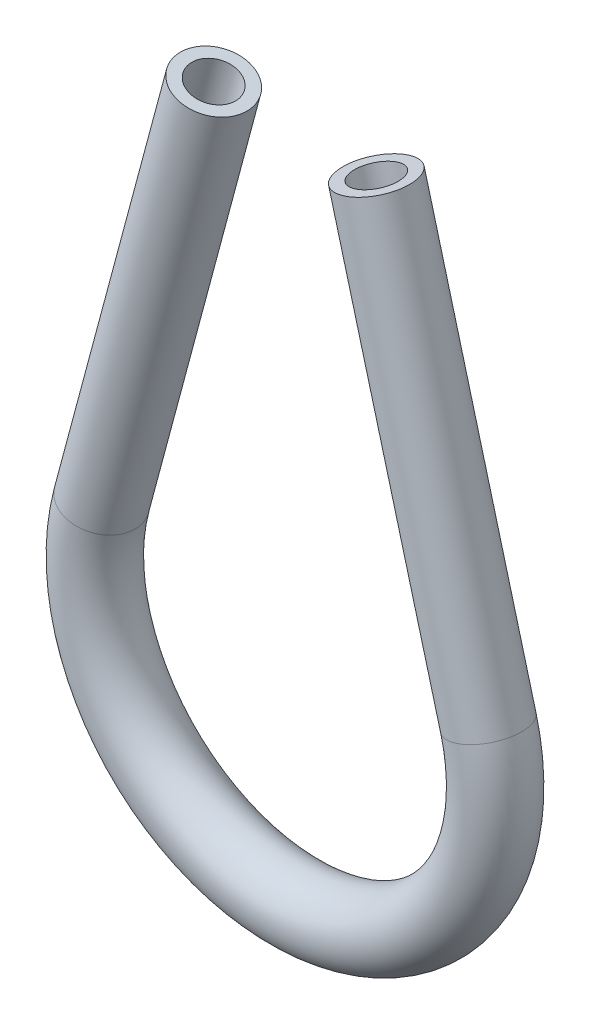
from build123d import *

# Parameters (mm, degrees)
SKETCH2_R   = 6.35
SKETCH2_R_2 = 4.1671875


with BuildPart() as part:
    # Sweep1: sweep along a path in Sketch1
    with BuildLine(Plane.XY) as sweep1_path:
        Line((-138.985158779, -15.429917513), (-159.618955177, -92.436294023))
        ThreePointArc((-159.618955177, -92.436294023), (-124.004465969, -138.85), (-88.389976761, -92.436294023))
        Line((-88.389976761, -92.436294023), (-109.023773159, -15.429917513))
    # Sketch2 → Sweep1 (sweep)
    with BuildSketch(Plane(origin=(-3.445728615, 12.859634261, 0), x_dir=(0.965925826, 0.258819045, 0), z_dir=(0.258819045, -0.965925826, 0))):
        with Locations((-109.302434691, 0)):
            Circle(SKETCH2_R)
        with Locations((-109.302434691, 0)):
            Circle(SKETCH2_R_2, mode=Mode.SUBTRACT)
    sweep(path=sweep1_path.line)


solid = part.part
